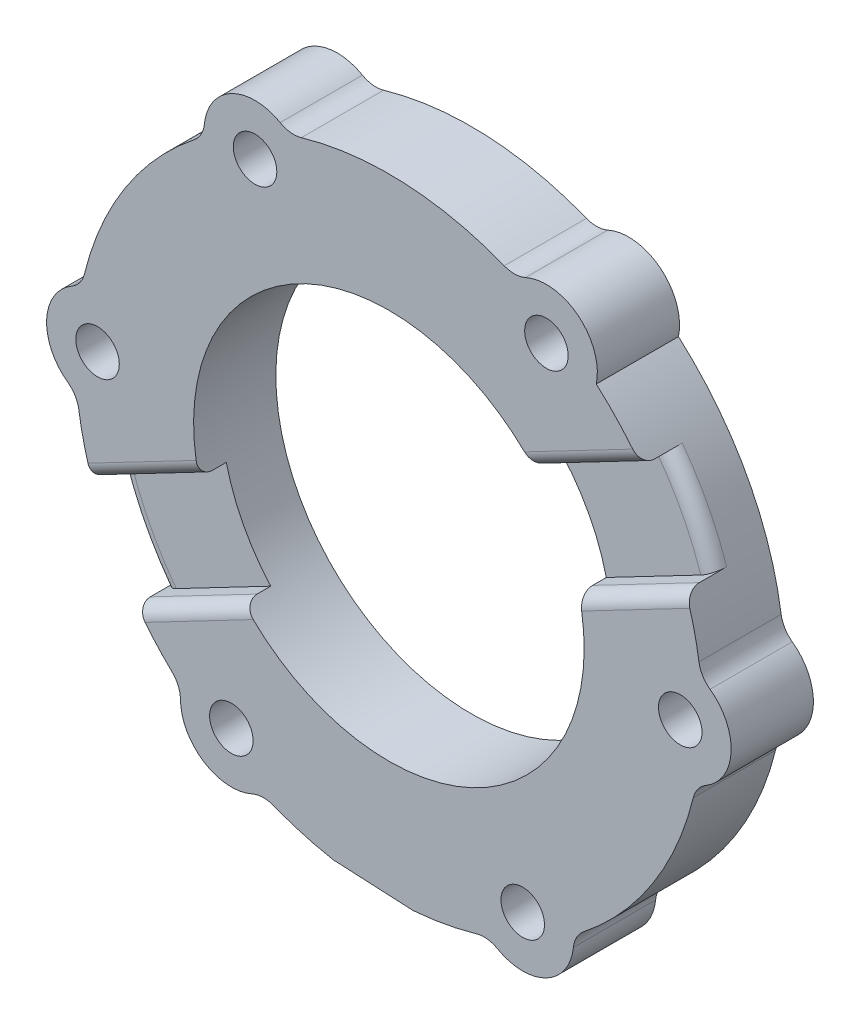
from build123d import *

# Parameters (mm, degrees)
SKETCH1_R           = 25
SKETCH1_R_2         = 14.25
BOSS_EXTRUDE1_DEPTH = 6
CUT_EXTRUDE1_REACH  = 8
CUT_EXTRUDE2_REACH  = 8
SKETCH3_R           = 1.5875
CUT_EXTRUDE3_DEPTH  = 2
CUT_EXTRUDE4_START  = -6.000001
SKETCH5_R           = 41.768296762
CUT_EXTRUDE4_DEPTH  = 6.000001
FILLET1_R           = 1


with BuildPart() as part:
    # Sketch1 → Boss-Extrude1 (new body)
    with BuildSketch(Plane.XY):
        Circle(SKETCH1_R)
        Circle(SKETCH1_R_2, mode=Mode.SUBTRACT)
    extrude(amount=BOSS_EXTRUDE1_DEPTH)

    # Sketch2 → Cut-Extrude1 (cut, up to next)
    with BuildSketch(Plane.XY.offset(6), mode=Mode.PRIVATE) as cut_extrude1_sk1:
        with BuildLine():
            Line((-11.636735818, -22.126598914), (9.351350952, -23.185172748))
            ThreePointArc((9.351350952, -23.185172748), (-1.259321499, -24.968262041), (-11.636735818, -22.126598914))
        make_face()
    cut_extrude1_tool1 = extrude(cut_extrude1_sk1.sketch, amount=-CUT_EXTRUDE1_REACH, mode=Mode.PRIVATE) & part.part
    add(cut_extrude1_tool1.solids().sort_by_distance((-1.189534, -23.584609, 6))[0], mode=Mode.SUBTRACT)

    # Sketch3 → Cut-Extrude2 (cut, up to next)
    with BuildSketch(Plane(origin=(0, 0, 0), x_dir=(-1, 0, 0), z_dir=(0, 0, -1)), mode=Mode.PRIVATE) as cut_extrude2_sk1:
        with Locations((11.49485864, -17.913013938)):
            Circle(SKETCH3_R)
    cut_extrude2_tool1 = extrude(cut_extrude2_sk1.sketch, amount=-CUT_EXTRUDE2_REACH, mode=Mode.PRIVATE) & part.part
    add(cut_extrude2_tool1.solids().sort_by_distance((-11.494859, -17.913014, 0))[0], mode=Mode.SUBTRACT)
    # Sketch3 → Cut-Extrude2 (cut, up to next)
    with BuildSketch(Plane(origin=(0, 0, 0), x_dir=(-1, 0, 0), z_dir=(0, 0, -1)), mode=Mode.PRIVATE) as cut_extrude2_sk2:
        with Locations((21.260554449, 0.998332626)):
            Circle(SKETCH3_R)
    cut_extrude2_tool2 = extrude(cut_extrude2_sk2.sketch, amount=-CUT_EXTRUDE2_REACH, mode=Mode.PRIVATE) & part.part
    add(cut_extrude2_tool2.solids().sort_by_distance((-21.260554, 0.998333, 0))[0], mode=Mode.SUBTRACT)
    # Sketch3 → Cut-Extrude2 (cut, up to next)
    with BuildSketch(Plane(origin=(0, 0, 0), x_dir=(-1, 0, 0), z_dir=(0, 0, -1)), mode=Mode.PRIVATE) as cut_extrude2_sk3:
        with Locations((9.765695809, 18.911346564)):
            Circle(SKETCH3_R)
    cut_extrude2_tool3 = extrude(cut_extrude2_sk3.sketch, amount=-CUT_EXTRUDE2_REACH, mode=Mode.PRIVATE) & part.part
    add(cut_extrude2_tool3.solids().sort_by_distance((-9.765696, 18.911347, 0))[0], mode=Mode.SUBTRACT)
    # Sketch3 → Cut-Extrude2 (cut, up to next)
    with BuildSketch(Plane(origin=(0, 0, 0), x_dir=(-1, 0, 0), z_dir=(0, 0, -1)), mode=Mode.PRIVATE) as cut_extrude2_sk4:
        with Locations((-11.49485864, 17.913013938)):
            Circle(SKETCH3_R)
    cut_extrude2_tool4 = extrude(cut_extrude2_sk4.sketch, amount=-CUT_EXTRUDE2_REACH, mode=Mode.PRIVATE) & part.part
    add(cut_extrude2_tool4.solids().sort_by_distance((11.494859, 17.913014, 0))[0], mode=Mode.SUBTRACT)
    # Sketch3 → Cut-Extrude2 (cut, up to next)
    with BuildSketch(Plane(origin=(0, 0, 0), x_dir=(-1, 0, 0), z_dir=(0, 0, -1)), mode=Mode.PRIVATE) as cut_extrude2_sk5:
        with Locations((-21.260554449, -0.998332626)):
            Circle(SKETCH3_R)
    cut_extrude2_tool5 = extrude(cut_extrude2_sk5.sketch, amount=-CUT_EXTRUDE2_REACH, mode=Mode.PRIVATE) & part.part
    add(cut_extrude2_tool5.solids().sort_by_distance((21.260554, -0.998333, 0))[0], mode=Mode.SUBTRACT)
    # Sketch3 → Cut-Extrude2 (cut, up to next)
    with BuildSketch(Plane(origin=(0, 0, 0), x_dir=(-1, 0, 0), z_dir=(0, 0, -1)), mode=Mode.PRIVATE) as cut_extrude2_sk6:
        with Locations((-9.765695809, -18.911346564)):
            Circle(SKETCH3_R)
    cut_extrude2_tool6 = extrude(cut_extrude2_sk6.sketch, amount=-CUT_EXTRUDE2_REACH, mode=Mode.PRIVATE) & part.part
    add(cut_extrude2_tool6.solids().sort_by_distance((9.765696, -18.911347, 0))[0], mode=Mode.SUBTRACT)

    # Sketch4 → Cut-Extrude3 (cut)
    with BuildSketch(Plane.XY.offset(6)):
        Polygon((12.56074277, 10.510839218), (35.025911551, 22.247124987), (38.267200626, 16.04276804), (15.802031846, 4.306482271), (-51.191313487, -30.692277506), (-54.432602563, -24.487920559), align=None)
    extrude(amount=-CUT_EXTRUDE3_DEPTH, mode=Mode.SUBTRACT)

    # Sketch5 → Cut-Extrude4 (cut)
    with BuildSketch(Plane.XY.offset(6).offset(CUT_EXTRUDE4_START)):
        Circle(SKETCH5_R)
        with BuildLine():
            ThreePointArc((-7.9313675, 22.143070177), (-11.470711058, 22.213121974), (-13.462706849, 19.286722677))
            ThreePointArc((-13.462706849, 19.286722677), (-13.698075607, 18.528505361), (-14.209890558, 17.921597291))
            ThreePointArc((-14.209890558, 17.921597291), (-19.249084936, 12.352221187), (-22.212464402, 5.450785662))
            ThreePointArc((-22.212464402, 5.450785662), (-22.550939275, 4.732644513), (-23.142145042, 4.202769347))
            ThreePointArc((-23.142145042, 4.202769347), (-24.972483456, 1.172633811), (-23.434145218, -2.015684796))
            ThreePointArc((-23.434145218, -2.015684796), (-22.89519414, -2.598628778), (-22.62550381, -3.345327563))
            ThreePointArc((-22.62550381, -3.345327563), (-20.32187981, -10.494085961), (-15.826751055, -16.511165622))
            ThreePointArc((-15.826751055, -16.511165622), (-15.374060012, -17.163364035), (-15.210777541, -17.940300831))
            ThreePointArc((-15.210777541, -17.940300831), (-13.501772398, -21.040488163), (-9.97143837, -21.302407473))
            ThreePointArc((-9.97143837, -21.302407473), (-9.197118534, -21.127134139), (-8.415613251, -21.266924854))
            ThreePointArc((-8.415613251, -21.266924854), (-1.072794873, -22.846307148), (6.385713347, -21.961951284))
            ThreePointArc((6.385713347, -21.961951284), (7.176879262, -21.896008547), (7.9313675, -22.143070177))
            ThreePointArc((7.9313675, -22.143070177), (11.470711058, -22.213121974), (13.462706849, -19.286722677))
            ThreePointArc((13.462706849, -19.286722677), (13.698075607, -18.528505361), (14.209890558, -17.921597291))
            ThreePointArc((14.209890558, -17.921597291), (19.249084936, -12.352221187), (22.212464402, -5.450785662))
            ThreePointArc((22.212464402, -5.450785662), (22.550939275, -4.732644513), (23.142145042, -4.202769347))
            ThreePointArc((23.142145042, -4.202769347), (24.972483456, -1.172633811), (23.434145218, 2.015684796))
            ThreePointArc((23.434145218, 2.015684796), (22.89519414, 2.598628778), (22.62550381, 3.345327563))
            ThreePointArc((22.62550381, 3.345327563), (20.100933566, 10.911329384), (15.131770312, 17.150340124))
            ThreePointArc((15.131770312, 17.150340124), (13.824370884, 20.808211783), (9.97143837, 21.302407473))
            ThreePointArc((9.97143837, 21.302407473), (9.197118534, 21.127134139), (8.415613251, 21.266924854))
            ThreePointArc((8.415613251, 21.266924854), (1.072794873, 22.846307148), (-6.385713347, 21.961951284))
            ThreePointArc((-6.385713347, 21.961951284), (-7.176879262, 21.896008547), (-7.9313675, 22.143070177))
        make_face(mode=Mode.SUBTRACT)
    extrude(amount=CUT_EXTRUDE4_DEPTH, mode=Mode.SUBTRACT)

    # Fillet1
    fillet1_edges = [part.edges().sort_by_distance(p)[0] for p in [
        (-14.517589627, -11.533137966, 6),
        (-20.271833071, -10.590440175, 4),
        (14.517589627, 11.533137966, 6),
        (20.271833071, 10.590440175, 4),
        (17.758878703, 5.328781019, 6),
        (-17.758878703, -5.328781019, 6),
    ]]
    fillet(fillet1_edges, radius=FILLET1_R)


solid = part.part
